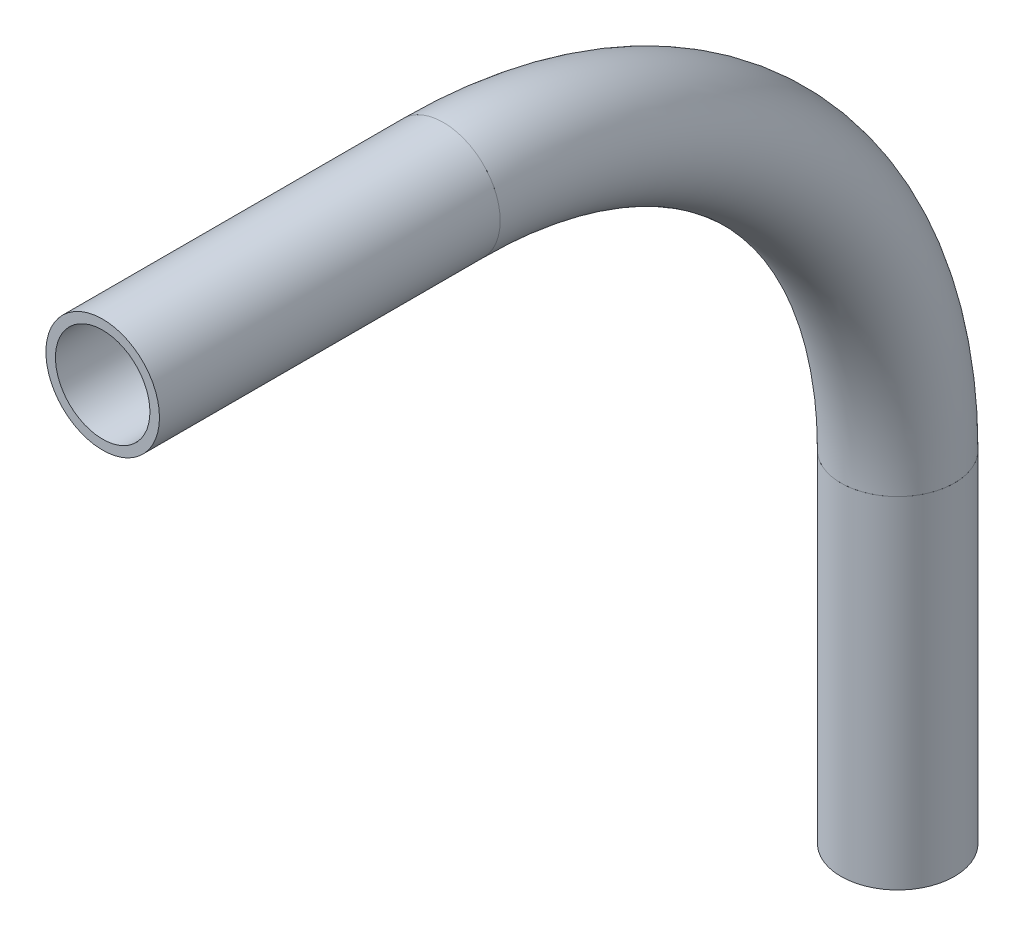
from build123d import *

# Parameters (mm, degrees)
SKETCH11_ON_SEGMENT_1_R   = 6.35
SKETCH11_ON_SEGMENT_1_R_2 = 5.2832
PIPE_0_5_SCH_40_1_DEPTH   = 38.1
SKETCH11_ON_SEGMENT_2_R   = 6.35
SKETCH11_ON_SEGMENT_2_R_2 = 5.2832
PIPE_0_5_SCH_40_1_2_ANGLE = 90
SKETCH11_R                = 6.35
SKETCH11_R_2              = 5.2832
PIPE_0_5_SCH_40_1_3_DEPTH = 38.1


with BuildPart() as part:
    # Sketch11 on segment 1 (carried to segment 1) → Pipe 0.5 SCH 40(1) (new body)
    with BuildSketch(Plane(origin=(0, -256.524515023, 363.571235239), x_dir=(0, 1, 0), z_dir=(0, 0, -1))):
        Circle(SKETCH11_ON_SEGMENT_1_R)
        Circle(SKETCH11_ON_SEGMENT_1_R_2, mode=Mode.SUBTRACT)
    extrude(amount=PIPE_0_5_SCH_40_1_DEPTH)


with BuildPart() as body_2:
    # Sketch11 on segment 2 (carried to the start of arc 2) → Pipe 0.5 SCH 40_1 2 (revolve)
    with BuildSketch(Plane(origin=(0, -256.524515023, 325.471235239), x_dir=(0, 1, 0), z_dir=(0, 0, -1))):
        Circle(SKETCH11_ON_SEGMENT_2_R)
        Circle(SKETCH11_ON_SEGMENT_2_R_2, mode=Mode.SUBTRACT)
    revolve(axis=Axis((0, -307.324515023, 325.471235239), (-1, 0, 0)), revolution_arc=PIPE_0_5_SCH_40_1_2_ANGLE)


with BuildPart() as body_3:
    # Sketch11 → Pipe 0.5 SCH 40_1 3 (new body)
    with BuildSketch(Plane(origin=(0, -307.324515023, 274.671235239), x_dir=(0, 0, -1), z_dir=(0, -1, 0))):
        Circle(SKETCH11_R)
        Circle(SKETCH11_R_2, mode=Mode.SUBTRACT)
    extrude(amount=PIPE_0_5_SCH_40_1_3_DEPTH)


solid = Compound([part.part, body_2.part, body_3.part])
